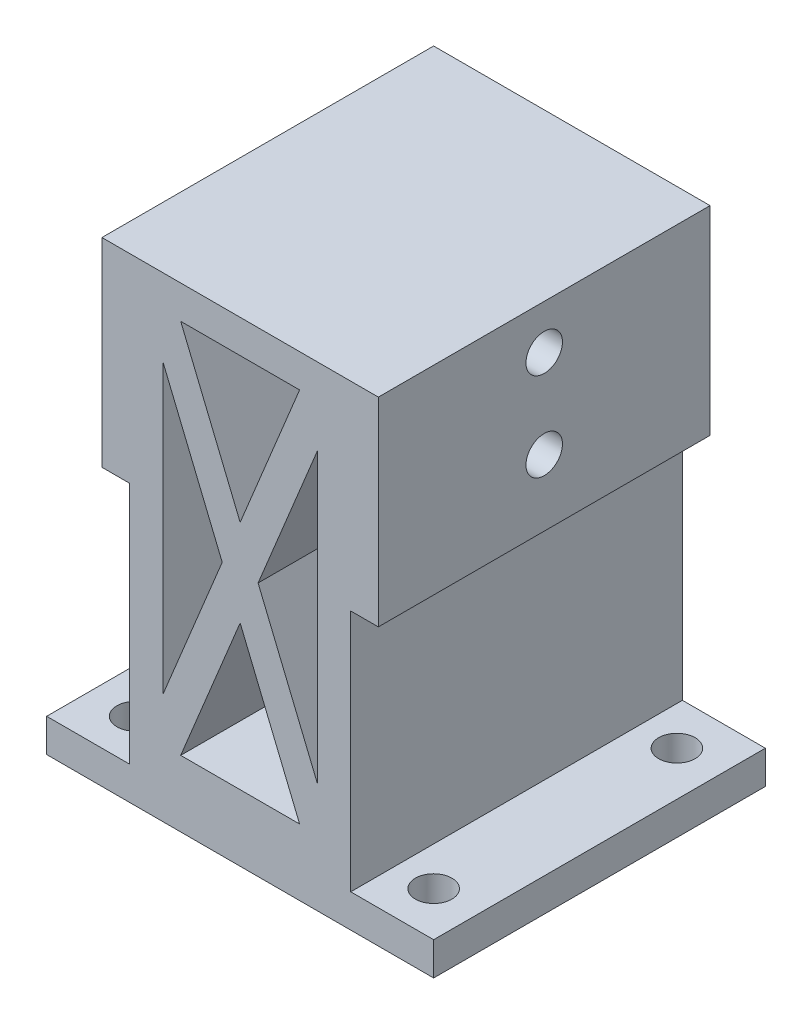
from build123d import *

# Parameters (mm, degrees)
SKETCH1_W           = 35
SKETCH1_H           = 30
BOSS_EXTRUDE1_DEPTH = 1.5
SKETCH2_R           = 1.65
CUT_EXTRUDE1_DEPTH  = 3
SKETCH3_W           = 20
SKETCH3_H           = 30
BOSS_EXTRUDE2_DEPTH = 40
SKETCH4_W           = 30
SKETCH4_H           = 18
BOSS_EXTRUDE3_DEPTH = 2.5
CUT_EXTRUDE2_DEPTH  = 30
SKETCH7_R           = 1.65
CUT_EXTRUDE3_DEPTH  = 25


with BuildPart() as part:
    # Sketch1 → Boss-Extrude1 (new body, symmetric)
    with BuildSketch(Plane(origin=(0, 0, 0), x_dir=(1, 0, 0), z_dir=(0, 1, 0))):
        Rectangle(SKETCH1_W, SKETCH1_H)
    extrude(amount=BOSS_EXTRUDE1_DEPTH, both=True)

    # Sketch2 → Cut-Extrude1 (cut)
    with BuildSketch(Plane(origin=(0, 1.5, 0), x_dir=(1, 0, 0), z_dir=(0, 1, 0))):
        with Locations((-13.5, 11)):
            Circle(SKETCH2_R)
        with Locations((13.5, 11)):
            Circle(SKETCH2_R)
        with Locations((13.5, -11)):
            Circle(SKETCH2_R)
        with Locations((-13.5, -11)):
            Circle(SKETCH2_R)
    extrude(amount=-CUT_EXTRUDE1_DEPTH, mode=Mode.SUBTRACT)

    # Sketch3 → Boss-Extrude2 (add)
    with BuildSketch(Plane(origin=(0, 1.5, 0), x_dir=(1, 0, 0), z_dir=(0, 1, 0))):
        Rectangle(SKETCH3_W, SKETCH3_H)
    extrude(amount=BOSS_EXTRUDE2_DEPTH)

    # Sketch4 → Boss-Extrude3 (add)
    with BuildSketch(Plane(origin=(10, 0, 0), x_dir=(0, 0, -1), z_dir=(1, 0, 0))):
        with Locations((0, 32.5)):
            Rectangle(SKETCH4_W, SKETCH4_H)
    boss_extrude3 = extrude(amount=BOSS_EXTRUDE3_DEPTH)

    # Mirror1: Boss-Extrude3 across plane
    add(boss_extrude3.mirror(Plane(origin=(0, 0, 0), x_dir=(0, 0, 1), z_dir=(1, 0, 0))))

    # Sketch5 → Cut-Extrude2 (cut)
    with BuildSketch(Plane(origin=(0, 0, -15), x_dir=(-1, 0, 0), z_dir=(0, 0, -1))):
        Polygon((0, 25.439594924), (5.377813855, 38.5), (-5.377813855, 38.5), align=None)
        Polygon((7, 8.439594924), (7, 34.560405076), (1.622186145, 21.5), align=None)
        Polygon((-7, 8.439594924), (-1.622186145, 21.5), (-7, 34.560405076), align=None)
        Polygon((5.377813855, 4.5), (0, 17.560405076), (-5.377813855, 4.5), align=None)
    extrude(amount=-CUT_EXTRUDE2_DEPTH, mode=Mode.SUBTRACT)

    # Sketch7 → Cut-Extrude3 (cut)
    with BuildSketch(Plane.ZY.offset(12.5)):
        with Locations((0, 37.5)):
            Circle(SKETCH7_R)
        with Locations((0, 29.5)):
            Circle(SKETCH7_R)
    extrude(amount=-CUT_EXTRUDE3_DEPTH, mode=Mode.SUBTRACT)


solid = part.part
